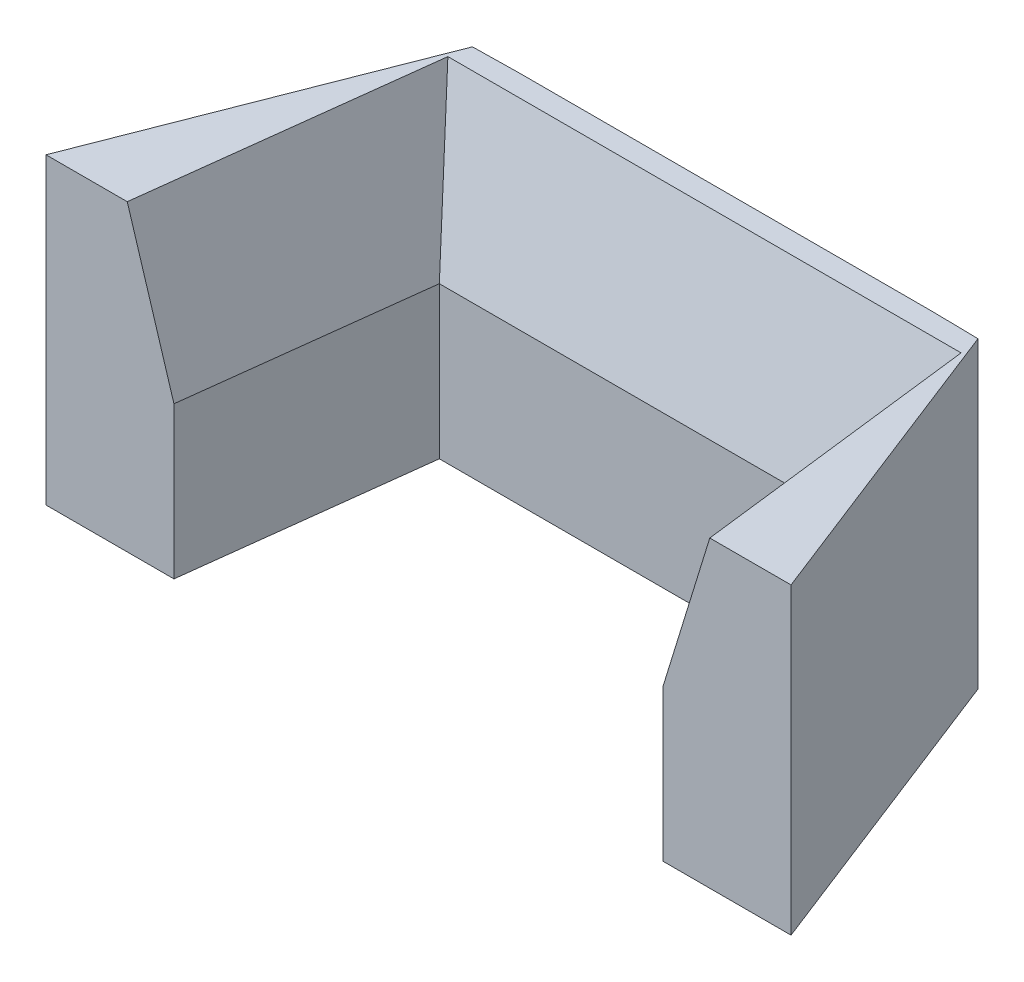
from build123d import *

# Parameters (mm, degrees)
SALIENTE_EXTRUIR1_DEPTH = 30
CORTAR_EXTRUIR2_DEPTH   = 90
CROQUIS5_W              = 20
CROQUIS5_H              = 2
SALIENTE_EXTRUIR2_DEPTH = 3
CHAFL_N1_SIZE           = 15
CHAFL_N1_SIZE2          = 4.585960222
CHAFL_N2_SIZE           = 15
CHAFL_N2_SIZE2          = 4.585960222
CHAFL_N3_SIZE           = 15
CHAFL_N3_SIZE2          = 4.873795443


with BuildPart() as part:
    # Croquis2 → Saliente-Extruir1 (new body)
    with BuildSketch(Plane(origin=(0, 0, 0), x_dir=(1, 0, 0), z_dir=(0, 1, 0))):
        Polygon((4.293050572, 35.408576274), (-0.206949428, 35.33296049), (-14, 0), (0, 0), (3.44434788, 28.408576274), align=None)
        Polygon((45.293050572, 35.408576274), (4.293050572, 35.408576274), (3.44434788, 28.408576274), (46.141753264, 28.408576274), align=None)
        Polygon((49.793050572, 35.33296049), (45.293050572, 35.408576274), (46.141753264, 28.408576274), (49.586101144, 0), (63.586101144, 0), align=None)
    extrude(amount=SALIENTE_EXTRUIR1_DEPTH)

    # Croquis4 → Cortar-Extruir2 (cut, symmetric)
    with BuildSketch(Plane(origin=(0, 0, 0), x_dir=(0, 0, -1), z_dir=(1, 0, 0))):
        Polygon((0, 0), (5, 0), (5, 30), (-4.90661078, 30), (-4.90661078, 0), align=None)
    extrude(amount=CORTAR_EXTRUIR2_DEPTH, both=True, mode=Mode.SUBTRACT)

    # Croquis5 → Saliente-Extruir2 (add)
    with BuildSketch(Plane(origin=(0, 0, 0), x_dir=(-1, 0, 0), z_dir=(0, -1, 0))):
        with Locations((-24.793050572, 32.408576274)):
            Rectangle(CROQUIS5_W, CROQUIS5_H)
    extrude(amount=SALIENTE_EXTRUIR2_DEPTH)

    # Chaflán1
    chafl_n1_edges = [part.edges().sort_by_distance(p)[0] for p in [
        (2.025282044, 30, -16.704288137),
    ]]
    chafl_n1_side = [part.faces().sort_by_distance(p)[0] for p in [
        (2.025282044, 15, -16.704288137),
    ]]
    chamfer(chafl_n1_edges, length=CHAFL_N1_SIZE, length2=CHAFL_N1_SIZE2, reference=chafl_n1_side[0])

    # Chaflán2
    chafl_n2_edges = [part.edges().sort_by_distance(p)[0] for p in [
        (47.5608191, 30, -16.704288137),
    ]]
    chafl_n2_side = [part.faces().sort_by_distance(p)[0] for p in [
        (47.5608191, 15, -16.704288137),
    ]]
    chamfer(chafl_n2_edges, length=CHAFL_N2_SIZE, length2=CHAFL_N2_SIZE2, reference=chafl_n2_side[0])

    # Chaflán3
    chafl_n3_edges = [part.edges().sort_by_distance(p)[0] for p in [
        (24.793050572, 30, -28.408576274),
    ]]
    chafl_n3_side = [part.faces().sort_by_distance(p)[0] for p in [
        (24.793050572, 15.5132008, -28.408576274),
    ]]
    chamfer(chafl_n3_edges, length=CHAFL_N3_SIZE, length2=CHAFL_N3_SIZE2, reference=chafl_n3_side[0])


solid = part.part
